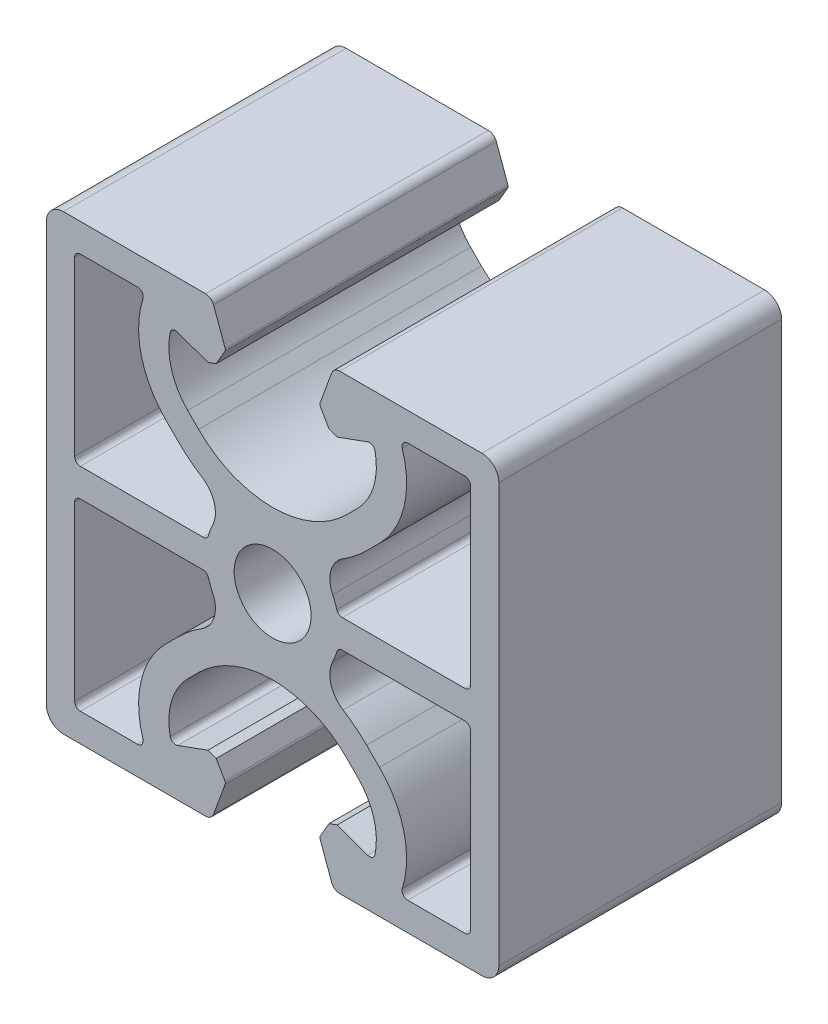
from build123d import *

# Parameters (mm, degrees)
SK_MAIN_EXTRUSION_R  = 3.4
MAIN_EXTRUSION_DEPTH = 25


with BuildPart() as part:
    # Sk Main Extrusion → Main Extrusion (new body)
    with BuildSketch(Plane.XY):
        with BuildLine():
            Line((-4.190076845, 16.671180212), (-5.222054351, 19.506515107))
            ThreePointArc((-5.222054351, 19.506515107), (-5.496641489, 19.864364033), (-5.926823816, 20))
            Line((-5.926823816, 20), (-18.5, 20))
            ThreePointArc((-18.5, 20), (-19.560660172, 19.560660172), (-20, 18.5))
            Line((-20, 18.5), (-20, -18.5))
            ThreePointArc((-20, -18.5), (-19.560660172, -19.560660172), (-18.5, -20))
            Line((-18.5, -20), (-5.926823816, -20))
            ThreePointArc((-5.926823816, -20), (-5.496641489, -19.864364033), (-5.222054351, -19.506515107))
            Line((-5.222054351, -19.506515107), (-4.190076845, -16.671180212))
            ThreePointArc((-4.190076845, -16.671180212), (-4.175951325, -16.563886241), (-4.208493649, -16.460675177))
            Line((-4.208493649, -16.460675177), (-4.987558066, -15.111296024))
            Line((-4.987558066, -15.111296024), (-5.718509166, -14.845251581))
            Line((-5.718509166, -14.845251581), (-8.396186179, -15.81984631))
            ThreePointArc((-8.396186179, -15.81984631), (-8.811074612, -15.786489799), (-9.056960151, -15.450654467))
            ThreePointArc((-9.056960151, -15.450654467), (-8.933433013, -12.665882372), (-7.504160339, -10.272684887))
            Line((-7.504160339, -10.272684887), (-6.540737726, -9.309262274))
            ThreePointArc((-6.540737726, -9.309262274), (0, -6.6), (6.540737726, -9.309262274))
            Line((6.540737726, -9.309262274), (7.504160339, -10.272684887))
            ThreePointArc((7.504160339, -10.272684887), (8.933433013, -12.665882372), (9.056960151, -15.450654467))
            ThreePointArc((9.056960151, -15.450654467), (8.811074612, -15.786489799), (8.396186179, -15.81984631))
            Line((8.396186179, -15.81984631), (5.718509166, -14.845251581))
            Line((5.718509166, -14.845251581), (4.987558066, -15.111296024))
            Line((4.987558066, -15.111296024), (4.208493649, -16.460675177))
            ThreePointArc((4.208493649, -16.460675177), (4.175951325, -16.563886241), (4.190076845, -16.671180212))
            Line((4.190076845, -16.671180212), (5.222054351, -19.506515107))
            ThreePointArc((5.222054351, -19.506515107), (5.496641489, -19.864364033), (5.926823816, -20))
            Line((5.926823816, -20), (18.5, -20))
            ThreePointArc((18.5, -20), (19.560660172, -19.560660172), (20, -18.5))
            Line((20, -18.5), (20, 18.5))
            ThreePointArc((20, 18.5), (19.560660172, 19.560660172), (18.5, 20))
            Line((18.5, 20), (5.926823816, 20))
            ThreePointArc((5.926823816, 20), (5.496641489, 19.864364033), (5.222054351, 19.506515107))
            Line((5.222054351, 19.506515107), (4.190076845, 16.671180212))
            ThreePointArc((4.190076845, 16.671180212), (4.175951325, 16.563886241), (4.208493649, 16.460675177))
            Line((4.208493649, 16.460675177), (4.987558066, 15.111296024))
            Line((4.987558066, 15.111296024), (5.718509166, 14.845251581))
            Line((5.718509166, 14.845251581), (8.396186179, 15.81984631))
            ThreePointArc((8.396186179, 15.81984631), (8.811074612, 15.786489799), (9.056960151, 15.450654467))
            ThreePointArc((9.056960151, 15.450654467), (8.933433013, 12.665882372), (7.504160339, 10.272684887))
            Line((7.504160339, 10.272684887), (6.540737726, 9.309262274))
            ThreePointArc((6.540737726, 9.309262274), (0, 6.6), (-6.540737726, 9.309262274))
            Line((-6.540737726, 9.309262274), (-7.504160339, 10.272684887))
            ThreePointArc((-7.504160339, 10.272684887), (-8.933433013, 12.665882372), (-9.056960151, 15.450654467))
            ThreePointArc((-9.056960151, 15.450654467), (-8.811074612, 15.786489799), (-8.396186179, 15.81984631))
            Line((-8.396186179, 15.81984631), (-5.718509166, 14.845251581))
            Line((-5.718509166, 14.845251581), (-4.987558066, 15.111296024))
            Line((-4.987558066, 15.111296024), (-4.208493649, 16.460675177))
            ThreePointArc((-4.208493649, 16.460675177), (-4.175951325, 16.563886241), (-4.190076845, 16.671180212))
        make_face()
        Circle(SK_MAIN_EXTRUSION_R, mode=Mode.SUBTRACT)
        with BuildLine():
            Line((-8.308504679, 7.441495321), (-9.444282589, 8.577273231))
            ThreePointArc((-9.444282589, 8.577273231), (-11.611987193, 12.430514315), (-11.464011904, 16.849169473))
            ThreePointArc((-11.464011904, 16.849169473), (-11.537349181, 17.295452819), (-11.940719521, 17.5))
            Line((-11.940719521, 17.5), (-17, 17.5))
            ThreePointArc((-17, 17.5), (-17.353553391, 17.353553391), (-17.5, 17))
            Line((-17.5, 17), (-17.5, 1.75))
            ThreePointArc((-17.5, 1.75), (-17.353553391, 1.396446609), (-17, 1.25))
            Line((-17, 1.25), (-6.156094541, 1.25))
            ThreePointArc((-6.156094541, 1.25), (-5.854730455, 1.351026708), (-5.675149655, 1.61328125))
            ThreePointArc((-5.675149655, 1.61328125), (-5.51245547, 2.10305366), (-5.307583096, 2.576734694))
            ThreePointArc((-5.307583096, 2.576734694), (-5.153883821, 4.359333373), (-6.230846881, 5.788120301))
            ThreePointArc((-6.230846881, 5.788120301), (-7.316529108, 6.555931161), (-8.308504679, 7.441495321))
        make_face(mode=Mode.SUBTRACT)
        with BuildLine():
            Line((-17.5, -1.75), (-17.5, -17))
            ThreePointArc((-17.5, -17), (-17.353553391, -17.353553391), (-17, -17.5))
            Line((-17, -17.5), (-11.940719521, -17.5))
            ThreePointArc((-11.940719521, -17.5), (-11.537349181, -17.295452819), (-11.464011904, -16.849169473))
            ThreePointArc((-11.464011904, -16.849169473), (-11.611987193, -12.430514315), (-9.444282589, -8.577273231))
            Line((-9.444282589, -8.577273231), (-8.308504679, -7.441495321))
            ThreePointArc((-8.308504679, -7.441495321), (-7.316529108, -6.555931161), (-6.230846881, -5.788120301))
            ThreePointArc((-6.230846881, -5.788120301), (-5.153883821, -4.359333373), (-5.307583096, -2.576734694))
            ThreePointArc((-5.307583096, -2.576734694), (-5.51245547, -2.10305366), (-5.675149655, -1.61328125))
            ThreePointArc((-5.675149655, -1.61328125), (-5.854730455, -1.351026708), (-6.156094541, -1.25))
            Line((-6.156094541, -1.25), (-17, -1.25))
            ThreePointArc((-17, -1.25), (-17.353553391, -1.396446609), (-17.5, -1.75))
        make_face(mode=Mode.SUBTRACT)
        with BuildLine():
            Line((9.444282589, 8.577273231), (8.308504679, 7.441495321))
            ThreePointArc((8.308504679, 7.441495321), (7.316529108, 6.555931161), (6.230846881, 5.788120301))
            ThreePointArc((6.230846881, 5.788120301), (5.153883821, 4.359333373), (5.307583096, 2.576734694))
            ThreePointArc((5.307583096, 2.576734694), (5.51245547, 2.10305366), (5.675149655, 1.61328125))
            ThreePointArc((5.675149655, 1.61328125), (5.854730455, 1.351026708), (6.156094541, 1.25))
            Line((6.156094541, 1.25), (17, 1.25))
            ThreePointArc((17, 1.25), (17.353553391, 1.396446609), (17.5, 1.75))
            Line((17.5, 1.75), (17.5, 17))
            ThreePointArc((17.5, 17), (17.353553391, 17.353553391), (17, 17.5))
            Line((17, 17.5), (11.940719521, 17.5))
            ThreePointArc((11.940719521, 17.5), (11.537349181, 17.295452819), (11.464011904, 16.849169473))
            ThreePointArc((11.464011904, 16.849169473), (11.611987193, 12.430514315), (9.444282589, 8.577273231))
        make_face(mode=Mode.SUBTRACT)
        with BuildLine():
            Line((8.308504679, -7.441495321), (9.444282589, -8.577273231))
            ThreePointArc((9.444282589, -8.577273231), (11.611987193, -12.430514315), (11.464011904, -16.849169473))
            ThreePointArc((11.464011904, -16.849169473), (11.537349181, -17.295452819), (11.940719521, -17.5))
            Line((11.940719521, -17.5), (17, -17.5))
            ThreePointArc((17, -17.5), (17.353553391, -17.353553391), (17.5, -17))
            Line((17.5, -17), (17.5, -1.75))
            ThreePointArc((17.5, -1.75), (17.353553391, -1.396446609), (17, -1.25))
            Line((17, -1.25), (6.156094541, -1.25))
            ThreePointArc((6.156094541, -1.25), (5.854730455, -1.351026708), (5.675149655, -1.61328125))
            ThreePointArc((5.675149655, -1.61328125), (5.51245547, -2.10305366), (5.307583096, -2.576734694))
            ThreePointArc((5.307583096, -2.576734694), (5.153883821, -4.359333373), (6.230846881, -5.788120301))
            ThreePointArc((6.230846881, -5.788120301), (7.316529108, -6.555931161), (8.308504679, -7.441495321))
        make_face(mode=Mode.SUBTRACT)
    extrude(amount=-MAIN_EXTRUSION_DEPTH)


solid = part.part
